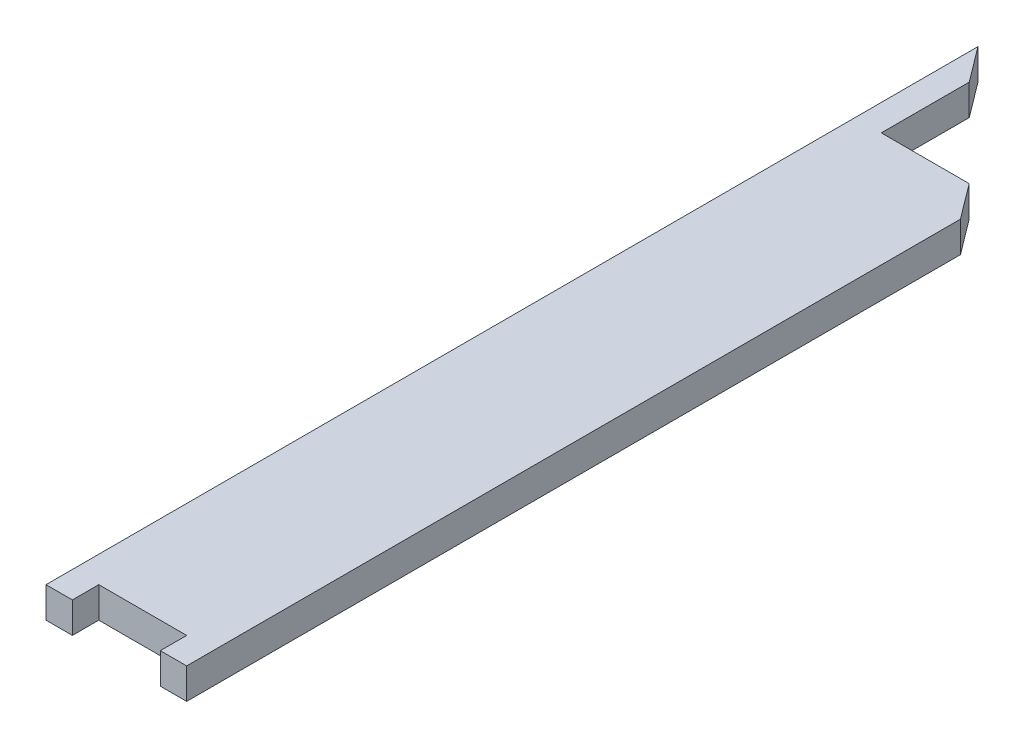
from build123d import *

# Parameters (mm, degrees)
EXTRUDE_1_DEPTH = 70


with BuildPart() as part:
    # 草图1 → 凸台-拉伸1 (new body)
    with BuildSketch(Plane(origin=(0, 0, 0), x_dir=(1, 0, 0), z_dir=(0, 1, 0))):
        Polygon((236.697586999, -27.173287726), (176.697586999, -27.173287726), (176.697586999, 32.826712274), (-23.302413001, 32.826712274), (-23.302413001, -27.173287726), (-83.302413001, -27.173287726), (-83.302413001, 2092.826712274), (-23.302413001, 2012.826712274), (-23.302413001, 1812.826712274), (176.697586999, 1812.826712274), (236.697586999, 1732.826712274), align=None)
    extrude(amount=EXTRUDE_1_DEPTH)


solid = part.part
